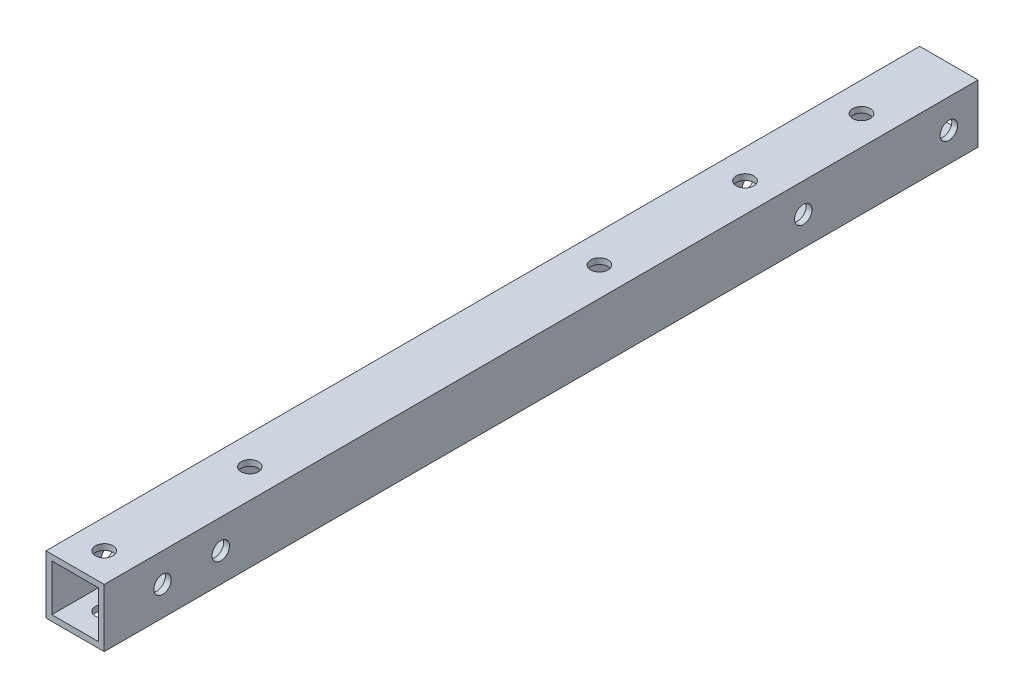
from build123d import *

# Parameters (mm, degrees)
SKETCH_1_W          = 10
SKETCH_1_H          = 10
SKETCH_1_W_2        = 8
SKETCH_1_H_2        = 8
EXTRUDE_1_DEPTH     = 150
SKETCH_2_R          = 1.5
CUT_EXTRUDE_1_DEPTH = 11
SKETCH_3_R          = 1.5
CUT_EXTRUDE_2_DEPTH = 11


with BuildPart() as part:
    # 草图1 → 拉伸-薄壁1 (new body)
    with BuildSketch(Plane.XY):
        with Locations((211.703793946, 99.48732034)):
            Rectangle(SKETCH_1_W, SKETCH_1_H)
        with Locations((211.703793946, 99.48732034)):
            Rectangle(SKETCH_1_W_2, SKETCH_1_H_2, mode=Mode.SUBTRACT)
    extrude(amount=EXTRUDE_1_DEPTH)

    # 草图2 → 切除-拉伸1 (cut, through all)
    with BuildSketch(Plane(origin=(216.703793946, 0, 0), x_dir=(0, 0, -1), z_dir=(1, 0, 0))):
        with Locations((-30, 99.48732034)):
            Circle(SKETCH_2_R)
        with Locations((-5, 99.48732034)):
            Circle(SKETCH_2_R)
        with Locations((-130, 99.48732034)):
            Circle(SKETCH_2_R)
        with Locations((-140, 99.48732034)):
            Circle(SKETCH_2_R)
    extrude(amount=-CUT_EXTRUDE_1_DEPTH, mode=Mode.SUBTRACT)

    # 草图3 → 切除-拉伸2 (cut, through all)
    with BuildSketch(Plane.XZ.offset(-94.48732034)):
        with Locations((211.703793946, 120)):
            Circle(SKETCH_3_R)
        with Locations((211.703793946, 35)):
            Circle(SKETCH_3_R)
        with Locations((211.703793946, 145)):
            Circle(SKETCH_3_R)
        with Locations((211.703793946, 60)):
            Circle(SKETCH_3_R)
        with Locations((211.703793946, 15)):
            Circle(SKETCH_3_R)
    extrude(amount=-CUT_EXTRUDE_2_DEPTH, mode=Mode.SUBTRACT)


solid = part.part
